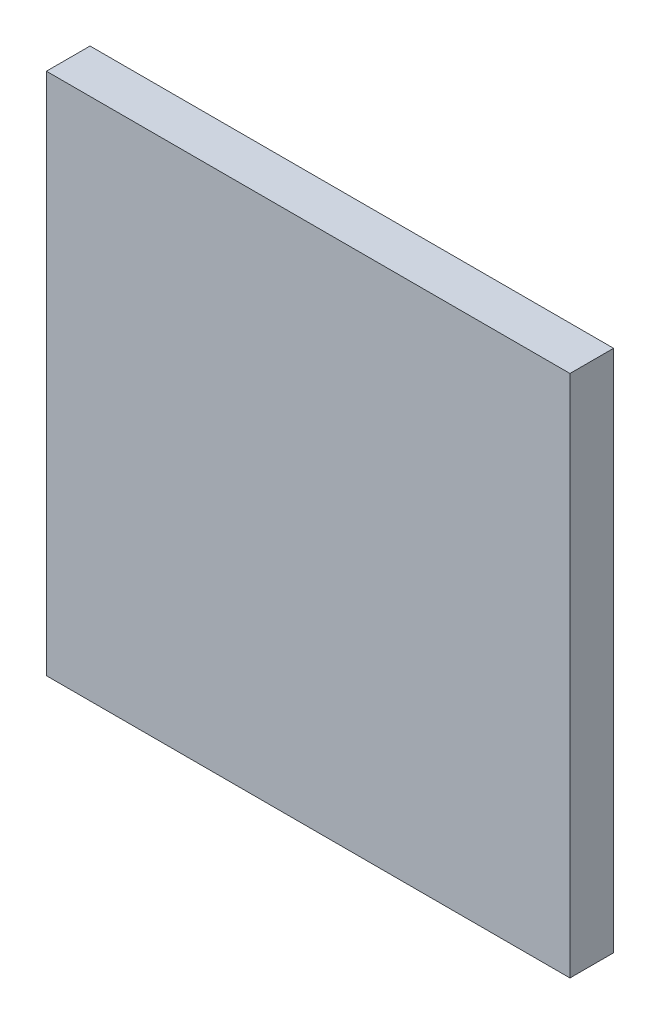
from build123d import *

# Parameters (mm, degrees)
SKETCH1_W      = 304.8
SKETCH1_H      = 304.8
EXTRUDE1_DEPTH = 25.4


with BuildPart() as part:
    # Sketch1 → Extrude1 (new body)
    with BuildSketch(Plane.XY):
        Rectangle(SKETCH1_W, SKETCH1_H)
    extrude(amount=-EXTRUDE1_DEPTH)


solid = part.part
